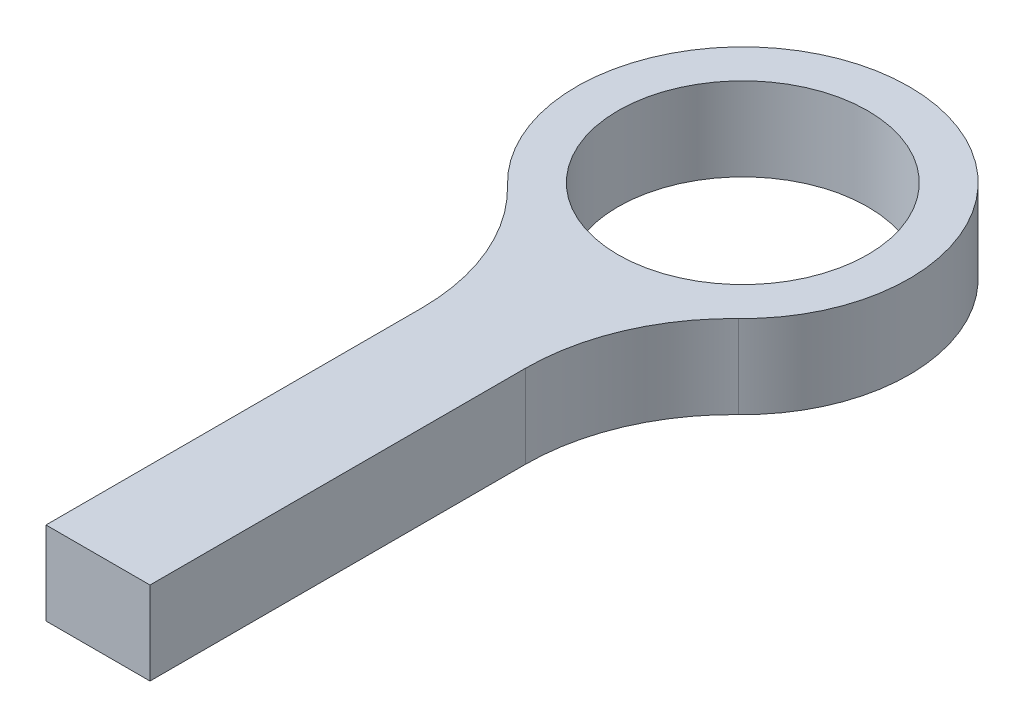
from build123d import *

# Parameters (mm, degrees)
SKETCH1_R           = 6
BOSS_EXTRUDE1_DEPTH = 4


with BuildPart() as part:
    # Sketch1 → Boss-Extrude1 (new body)
    with BuildSketch(Plane(origin=(0, 0, 0), x_dir=(1, 0, 0), z_dir=(0, 1, 0))):
        with BuildLine():
            Line((-2.5, -12.951833847), (-2.5, -31))
            Line((-2.5, -31), (2.5, -31))
            Line((2.5, -31), (2.5, -12.951833847))
            ThreePointArc((2.5, -12.951833847), (3.295532486, -9.043154047), (5.555555556, -5.756370599))
            ThreePointArc((5.555555556, -5.756370599), (0, 8), (-5.555555556, -5.756370599))
            ThreePointArc((-5.555555556, -5.756370599), (-3.295532486, -9.043154047), (-2.5, -12.951833847))
        make_face()
        Circle(SKETCH1_R, mode=Mode.SUBTRACT)
    extrude(amount=BOSS_EXTRUDE1_DEPTH)


solid = part.part
